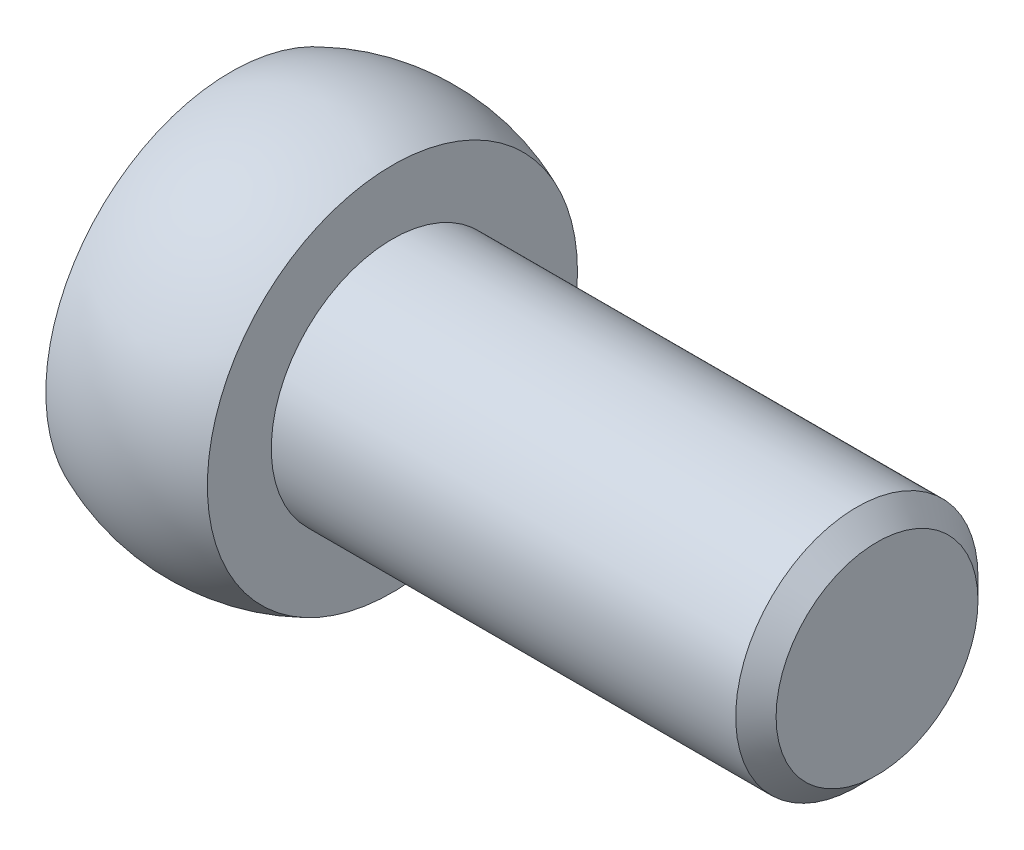
from build123d import *


with BuildPart() as part:
    # Эскиз1 → Повернуть1 (revolve)
    with BuildSketch(Plane.XY):
        with BuildLine():
            Line((0, 0), (0, 4.582575695))
            ThreePointArc((0, 4.582575695), (2, 5), (4, 4.582575695))
            Line((4, 4.582575695), (4, 3))
            Line((4, 3), (15.5, 3))
            Line((15.5, 3), (16, 2.5))
            Line((16, 2.5), (16, 0))
            Line((16, 0), (0, 0))
        make_face()
    revolve(axis=Axis((0, 0, 0), (-1, 0, 0)))


solid = part.part
